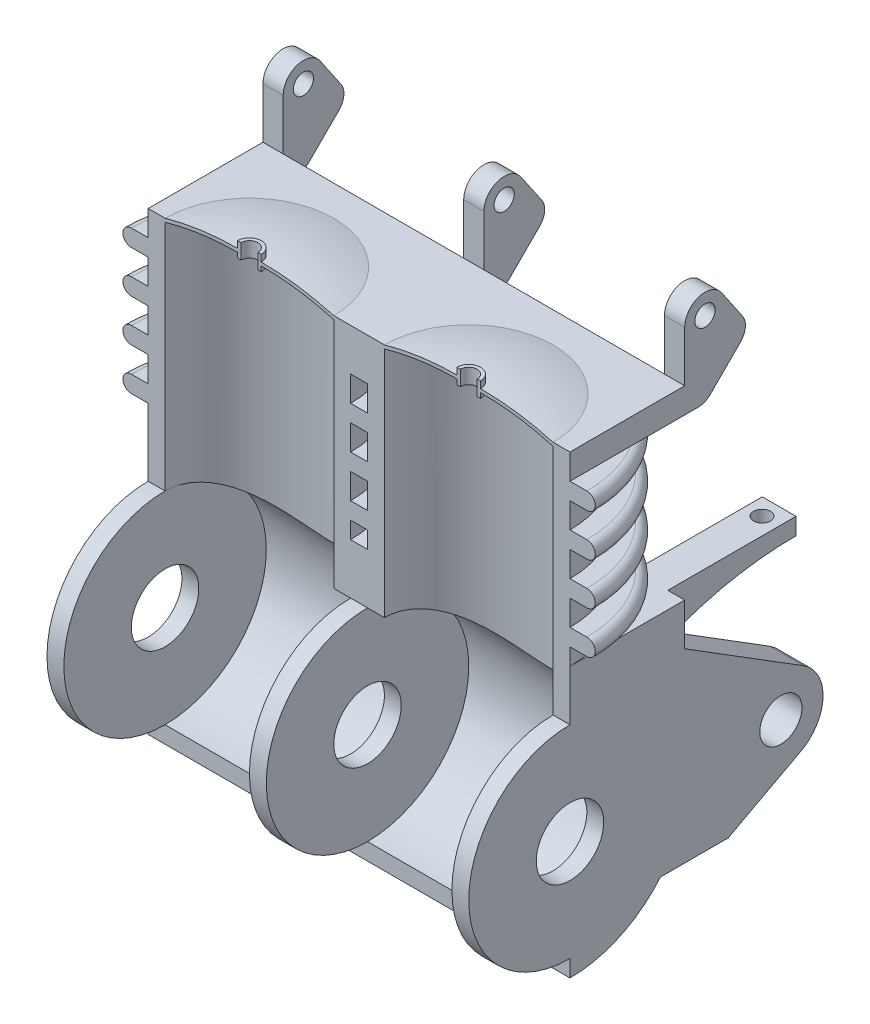
from build123d import *

# Parameters (mm, degrees)
BOSS_EXTRUDE1_DEPTH = 125
REVOLVE1_ANGLE      = 180
SKETCH14_R          = 60
CUT_EXTRUDE5_DEPTH  = 251
CUT_EXTRUDE6_START  = -56.833752
SKETCH20_R          = 50
CUT_EXTRUDE6_DEPTH  = 56.833752
SKETCH21_W          = 10
SKETCH21_H          = 40
BOSS_EXTRUDE4_DEPTH = 15
SKETCH23_R          = 6
BOSS_EXTRUDE5_DEPTH = 250
SKETCH25_W          = 107
SKETCH25_H          = 57
CUT_EXTRUDE8_DEPTH  = 36
BOSS_EXTRUDE8_DEPTH = 20
CUT_EXTRUDE12_START = -10.563293
SKETCH33_R          = 5
CUT_EXTRUDE12_DEPTH = 10.563293
SKETCH34_R          = 12.5
BOSS_EXTRUDE9_DEPTH = 20


with BuildPart() as part:
    # Sketch1 → Boss-Extrude1 (new body, symmetric)
    with BuildSketch(Plane(origin=(0, 0, 0), x_dir=(0, 0, -1), z_dir=(1, 0, 0))):
        with BuildLine():
            Line((0, 160), (68, 160))
            Line((68, 160), (68, 86.613247726))
            ThreePointArc((68, 86.613247726), (55.058729284, 26.773430282), (0, 0))
            Line((0, 0), (0, 160))
        make_face()
    extrude(amount=BOSS_EXTRUDE1_DEPTH, both=True)

    # Sketch6 → Revolve1 (revolve)
    with BuildSketch(Plane.XY):
        with BuildLine():
            Line((125, 160), (125, 170))
            Line((125, 170), (135, 170))
            ThreePointArc((135, 170), (140, 175), (135, 180))
            Line((135, 180), (125, 180))
            Line((125, 180), (125, 195))
            Line((125, 195), (135, 195))
            ThreePointArc((135, 195), (140, 200), (135, 205))
            Line((135, 205), (125, 205))
            Line((125, 205), (125, 220))
            Line((125, 220), (135, 220))
            ThreePointArc((135, 220), (140, 225), (135, 230))
            Line((135, 230), (125, 230))
            Line((125, 230), (125, 245))
            Line((125, 245), (135, 245))
            ThreePointArc((135, 245), (140, 250), (135, 255))
            Line((135, 255), (125, 255))
            Line((125, 255), (125, 270))
            Line((125, 270), (115, 270))
            ThreePointArc((115, 270), (93.708522212, 274.495240549), (72, 276.003311295))
            Line((72, 276.003311295), (72, 280.003311295))
            Line((72, 280.003311295), (70, 280.003311295))
            Line((70, 280.003311295), (70, 271.003311295))
            Line((70, 271.003311295), (72, 271.003311295))
            Line((72, 271.003311295), (72, 274.003311295))
            ThreePointArc((72, 274.003311295), (93.714131556, 272.474795587), (115, 267.919395046))
            Line((115, 267.919395046), (115, 160))
            Line((115, 160), (125, 160))
        make_face()
    revolve1 = revolve(axis=Axis((65, 17.777184471, 0), (0, 1, 0)), revolution_arc=REVOLVE1_ANGLE)

    # Sketch14 → Cut-Extrude5 (cut, through all)
    with BuildSketch(Plane(origin=(125, 0, 0), x_dir=(0, 0, -1), z_dir=(1, 0, 0))):
        with Locations((0, 70)):
            Circle(SKETCH14_R)
    extrude(amount=-CUT_EXTRUDE5_DEPTH, mode=Mode.SUBTRACT)

    # Sketch20 → Cut-Extrude6 (cut)
    with BuildSketch(Plane(origin=(0, 160, 0), x_dir=(1, 0, 0), z_dir=(0, 1, 0)).offset(CUT_EXTRUDE6_START)):
        with Locations((65, 0)):
            Circle(SKETCH20_R)
    cut_extrude6 = extrude(amount=CUT_EXTRUDE6_DEPTH, mode=Mode.SUBTRACT)

    # Mirror2: Revolve1, Cut-Extrude6 across plane
    add(revolve1.mirror(Plane(origin=(0, 0, 0), x_dir=(0, 0, 1), z_dir=(1, 0, 0))))
    add(cut_extrude6.mirror(Plane(origin=(0, 0, 0), x_dir=(0, 0, 1), z_dir=(1, 0, 0))), mode=Mode.SUBTRACT)

    # Sketch21 → Revolve2 (revolve)
    with BuildSketch(Plane.XY, mode=Mode.PRIVATE) as revolve2_sk:
        with Locations((-120, 110)):
            Rectangle(SKETCH21_W, SKETCH21_H)
        with Locations((0, 110)):
            Rectangle(SKETCH21_W, SKETCH21_H)
        with Locations((120, 110)):
            Rectangle(SKETCH21_W, SKETCH21_H)
    revolve(revolve2_sk.sketch.rotate(Axis((-162.156839323, 70, 0), (1, 0, 0)), 90), axis=Axis((-162.156839323, 70, 0), (1, 0, 0)))  # turned: the seam where the file's is

    # Sketch22 → Boss-Extrude4 (add)
    with BuildSketch(Plane(origin=(0, 270, 0), x_dir=(1, 0, 0), z_dir=(0, 1, 0))):
        with BuildLine():
            Line((-125, 0), (-125, 68))
            Line((-125, 68), (125, 68))
            Line((125, 68), (125, 0))
            ThreePointArc((125, 0), (65, 60), (5, 0))
            Line((5, 0), (-5, 0))
            ThreePointArc((-5, 0), (-65, 60), (-125, 0))
        make_face()
    extrude(amount=-BOSS_EXTRUDE4_DEPTH)

    # Sketch23 → Boss-Extrude5 (add)
    with BuildSketch(Plane(origin=(125, 0, 0), x_dir=(0, 0, -1), z_dir=(1, 0, 0))):
        with BuildLine():
            Line((102.264723864, 288.629772594), (89.917668636, 306.755727112))
            ThreePointArc((89.917668636, 306.755727112), (76.465316396, 311.467607066), (68, 300))
            Line((68, 300), (68, 255))
            Line((68, 255), (76, 255))
            ThreePointArc((76, 255), (79.826834324, 255.761204675), (83.071067812, 257.928932188))
            Line((83.071067812, 257.928932188), (101.071067812, 275.928932188))
            ThreePointArc((101.071067812, 275.928932188), (103.956126924, 282.064298836), (102.264723864, 288.629772594))
        make_face()
        with Locations((80, 300)):
            Circle(SKETCH23_R, mode=Mode.SUBTRACT)
    extrude(amount=-BOSS_EXTRUDE5_DEPTH)

    # Sketch25 → Cut-Extrude8 (cut)
    with BuildSketch(Plane(origin=(0, 0, -104), x_dir=(-1, 0, 0), z_dir=(0, 0, -1))):
        with Locations((-59.5, 283.5)):
            Rectangle(SKETCH25_W, SKETCH25_H)
        with Locations((59.5, 283.5)):
            Rectangle(SKETCH25_W, SKETCH25_H)
    extrude(amount=-CUT_EXTRUDE8_DEPTH, mode=Mode.SUBTRACT)

    # Sketch32 → Boss-Extrude8 (add)
    with BuildSketch(Plane(origin=(115, 0, 0), x_dir=(0, 0, -1), z_dir=(1, 0, 0))):
        with BuildLine():
            Line((68, 160), (143.993420768, 160))
            Line((143.993420768, 160), (143.993420768, 150))
            ThreePointArc((143.993420768, 150), (105.263587306, 146.214168703), (68, 135))
            Line((68, 135), (68, 160))
        make_face()
    boss_extrude8 = extrude(amount=-BOSS_EXTRUDE8_DEPTH)

    # Sketch33 → Cut-Extrude12 (cut)
    with BuildSketch(Plane(origin=(0, 160, 0), x_dir=(1, 0, 0), z_dir=(0, 1, 0)).offset(CUT_EXTRUDE12_START)):
        with Locations(Location((104.829114539, 133.993420768, 0), (0, 0, 270))):  # turned: the seam where the file's is
            Circle(SKETCH33_R)
    cut_extrude12 = extrude(amount=CUT_EXTRUDE12_DEPTH, mode=Mode.SUBTRACT)

    # Sketch34 → Boss-Extrude9 (add)
    with BuildSketch(Plane(origin=(125, 0, 0), x_dir=(0, 0, -1), z_dir=(1, 0, 0))):
        with BuildLine():
            Line((68, 135), (138.226901751, 91.214359997))
            ThreePointArc((138.226901751, 91.214359997), (149.985625558, 69.152347069), (136.758723807, 47.937987072))
            Line((136.758723807, 47.937987072), (93.721896373, 25))
            Line((93.721896373, 25), (53.619026474, 25))
            ThreePointArc((53.619026474, 25), (68.167770786, 54.089153823), (68, 86.613247726))
            Line((68, 86.613247726), (68, 135))
        make_face()
        with Locations((125, 70)):
            Circle(SKETCH34_R, mode=Mode.SUBTRACT)
    boss_extrude9 = extrude(amount=-BOSS_EXTRUDE9_DEPTH)

    # Mirror3: Boss-Extrude8, Cut-Extrude12, Boss-Extrude9 across plane
    add(boss_extrude8.mirror(Plane(origin=(0, 0, 0), x_dir=(0, 0, 1), z_dir=(1, 0, 0))))
    add(cut_extrude12.mirror(Plane(origin=(0, 0, 0), x_dir=(0, 0, 1), z_dir=(1, 0, 0))), mode=Mode.SUBTRACT)
    add(boss_extrude9.mirror(Plane(origin=(0, 0, 0), x_dir=(0, 0, 1), z_dir=(1, 0, 0))))


solid = part.part
